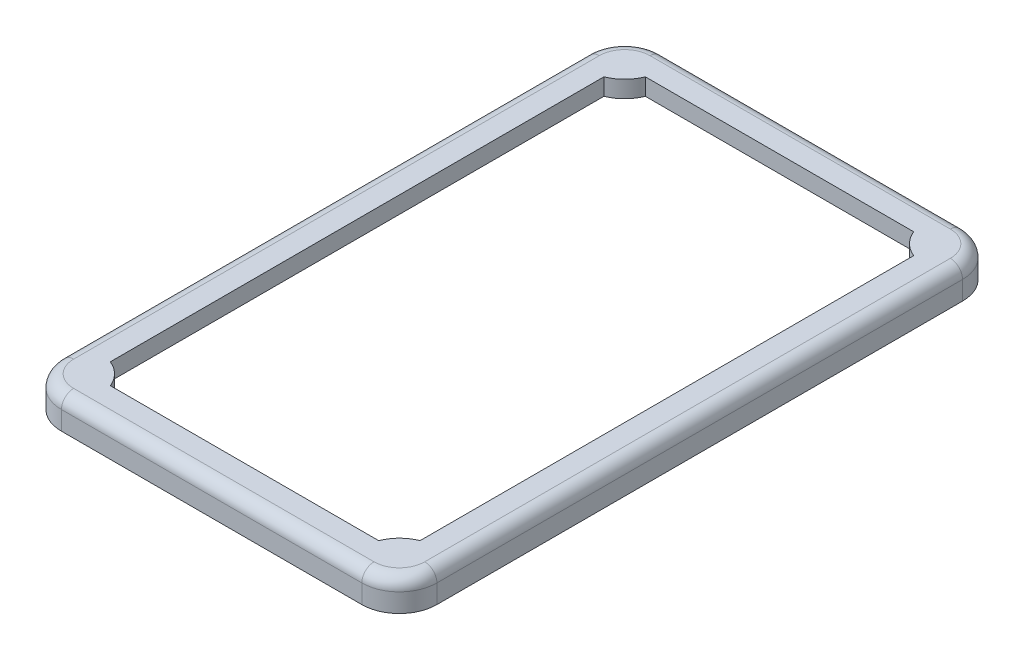
from build123d import *

# Parameters (mm, degrees)
SKETCH1_W                          = 40
SKETCH1_H                          = 64
SKETCH1_W_2                        = 36
SKETCH1_H_2                        = 60
BOSS_EXTRUDE1_DEPTH                = 3.3
SKETCH3_W                          = 36
SKETCH3_H                          = 60
BOSS_EXTRUDE2_DEPTH                = 1.8
FILLET1_R                          = 4
M2_2X0_45_TAPPED_HOLE1_D           = 1.75
M2_2X0_45_TAPPED_HOLE1_DEPTH       = 1.2
M2_2X0_45_TAPPED_HOLE1_CSINK_D     = 2.25
M2_2X0_45_TAPPED_HOLE1_CSINK_ANGLE = 90
M2_2X0_45_TAPPED_HOLE1_TIP         = 0.525753042
FILLET3_R                          = 1.3


with BuildPart() as part:
    # Sketch1 → Boss-Extrude1 (new body)
    with BuildSketch(Plane(origin=(0, 0, 0), x_dir=(1, 0, 0), z_dir=(0, 1, 0))):
        Rectangle(SKETCH1_W, SKETCH1_H)
        Rectangle(SKETCH1_W_2, SKETCH1_H_2, mode=Mode.SUBTRACT)
    extrude(amount=BOSS_EXTRUDE1_DEPTH)

    # Sketch3 → Boss-Extrude2 (add)
    with BuildSketch(Plane(origin=(0, 3.3, 0), x_dir=(1, 0, 0), z_dir=(0, 1, 0))):
        Rectangle(SKETCH3_W, SKETCH3_H)
        with BuildLine():
            ThreePointArc((14.291900756, 28.5), (15.171572875, 27.171572875), (16.5, 26.291900756))
            Line((16.5, 26.291900756), (16.5, -26.291900756))
            ThreePointArc((16.5, -26.291900756), (15.171572875, -27.171572875), (14.291900756, -28.5))
            Line((14.291900756, -28.5), (-14.291900756, -28.5))
            ThreePointArc((-14.291900756, -28.5), (-15.171572875, -27.171572875), (-16.5, -26.291900756))
            Line((-16.5, -26.291900756), (-16.5, 26.291900756))
            ThreePointArc((-16.5, 26.291900756), (-15.171572875, 27.171572875), (-14.291900756, 28.5))
            Line((-14.291900756, 28.5), (14.291900756, 28.5))
        make_face(mode=Mode.SUBTRACT)
    extrude(amount=-BOSS_EXTRUDE2_DEPTH)

    # Fillet1
    fillet1_edges = [part.edges().sort_by_distance(p)[0] for p in [
        (-20, 1.65, -32),
        (20, 1.65, -32),
        (20, 1.65, 32),
        (-20, 1.65, 32),
    ]]
    fillet(fillet1_edges, radius=FILLET1_R)

    # M2.2x0.45 Tapped Hole1
    with Locations(Plane.XZ.offset(-1.5)):
        with Locations((-16.585786438, 28.585786438), (16.585786438, 28.585786438), (-16.585786438, -28.585786438), (16.585786438, -28.585786438)):
            CounterSinkHole(M2_2X0_45_TAPPED_HOLE1_D / 2, M2_2X0_45_TAPPED_HOLE1_CSINK_D / 2, depth=M2_2X0_45_TAPPED_HOLE1_DEPTH, counter_sink_angle=M2_2X0_45_TAPPED_HOLE1_CSINK_ANGLE)
            with Locations((0, 0, -(M2_2X0_45_TAPPED_HOLE1_DEPTH + M2_2X0_45_TAPPED_HOLE1_TIP / 2))):  # 118° drill point
                Cone(0, M2_2X0_45_TAPPED_HOLE1_D / 2, M2_2X0_45_TAPPED_HOLE1_TIP, mode=Mode.SUBTRACT)

    # Fillet3
    fillet3_edges = [part.edges().sort_by_distance(p)[0] for p in [
        (0, 3.3, -32),
        (20, 3.3, 0),
        (-20, 3.3, 0),
        (0, 3.3, 32),
        (-18.828427125, 3.3, 30.828427125),
        (18.828427125, 3.3, 30.828427125),
        (-18.828427125, 3.3, -30.828427125),
        (18.828427125, 3.3, -30.828427125),
    ]]
    fillet(fillet3_edges, radius=FILLET3_R)


solid = part.part
